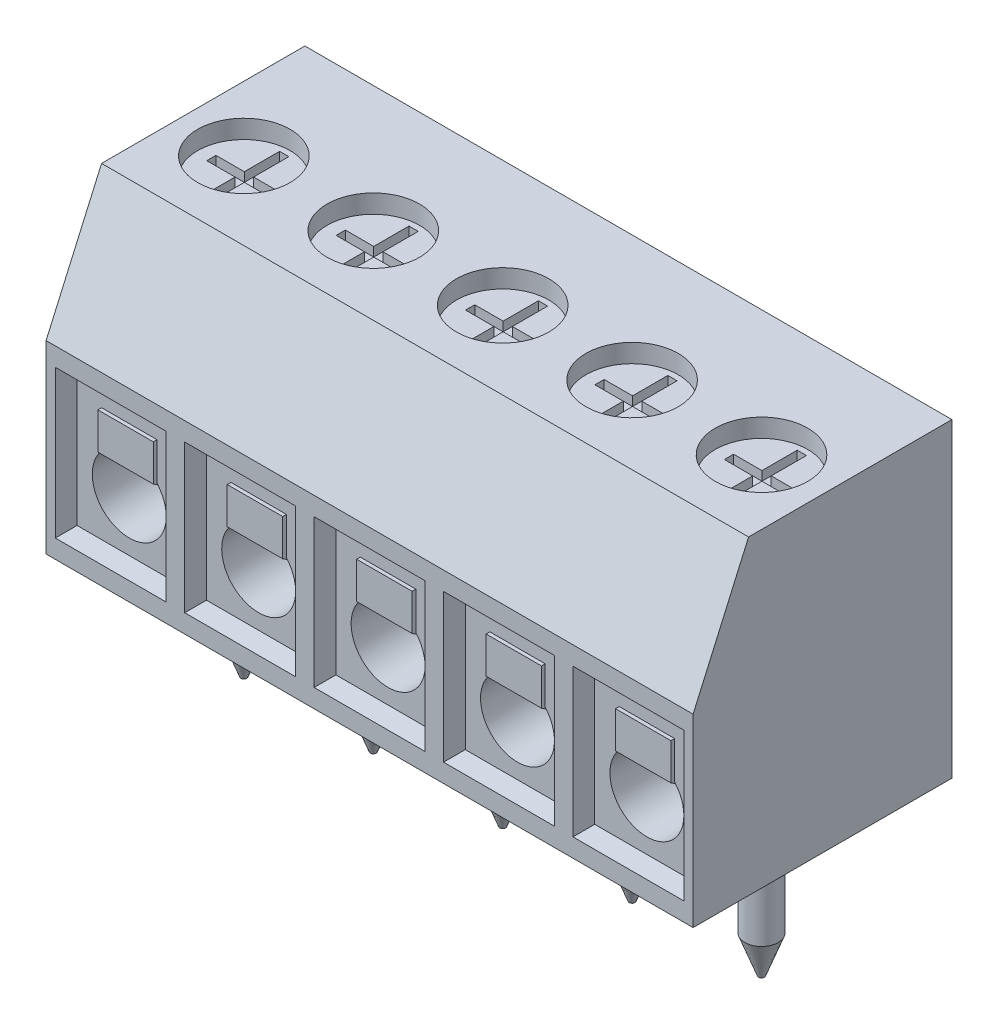
from build123d import *

# Parameters (mm, degrees)
BOSS_EXTRUDE1_DEPTH         = 17.5
SKETCH2_R                   = 1.25
CUT_EXTRUDE1_DEPTH          = 0.5
SKETCH3_W                   = 3
SKETCH3_H                   = 4
CUT_EXTRUDE2_DEPTH          = 0.5
CUT_EXTRUDE2_TAPER          = 10
SKETCH4_R                   = 1
CUT_EXTRUDE3_DEPTH          = 6
SKETCH6_R                   = 0.45
BOSS_EXTRUDE3_DEPTH         = 3.8
CHAMFER1_SIZE               = 1
CHAMFER1_SIZE2              = 0.371896666
EXTRUDE_THIN1_DEPTH         = 0.75
SKETCH8_W                   = 0.25
SKETCH8_H                   = 2.158330758
SKETCH8_W_2                 = 1.874325027
SKETCH8_H_2                 = 0.25
CUT_EXTRUDE_THIN1_DEPTH     = 0.25
LPATTERN1_COUNT             = 5
LPATTERN1_PITCH             = 3.5
CHAMFER1_OF_LPATTERN1_SIZE2 = 0.371896666
CHAMFER1_OF_LPATTERN1_SIZE  = 1


with BuildPart() as part:
    # Sketch1 → Boss-Extrude1 (new body)
    with BuildSketch(Plane(origin=(0, 0, 0), x_dir=(0, 0, -1), z_dir=(1, 0, 0))):
        Polygon((0, 5), (1.5, 8.4), (7, 8.4), (7, 0), (0, 0), align=None)
    extrude(amount=BOSS_EXTRUDE1_DEPTH)

    # Sketch2 → Cut-Extrude1 (cut)
    with BuildSketch(Plane(origin=(0, 8.4, 0), x_dir=(1, 0, 0), z_dir=(0, 1, 0))):
        with Locations((1.75, 3.6)):
            Circle(SKETCH2_R)
    cut_extrude1 = extrude(amount=-CUT_EXTRUDE1_DEPTH, mode=Mode.SUBTRACT)

    # Sketch3 → Cut-Extrude2 (cut)
    with BuildSketch(Plane.XY):
        with Locations((1.75, 2.5)):
            Rectangle(SKETCH3_W, SKETCH3_H)
    cut_extrude2 = extrude(amount=-CUT_EXTRUDE2_DEPTH, taper=CUT_EXTRUDE2_TAPER, mode=Mode.SUBTRACT)

    # Sketch4 → Cut-Extrude3 (cut)
    with BuildSketch(Plane.XY.offset(-0.5)):
        with Locations((1.75, 2)):
            Circle(SKETCH4_R)
    cut_extrude3 = extrude(amount=-CUT_EXTRUDE3_DEPTH, mode=Mode.SUBTRACT)

    # Sketch6 → Boss-Extrude3 (add)
    with BuildSketch(Plane.XZ):
        with Locations((1.75, -3.6)):
            Circle(SKETCH6_R)
    boss_extrude3 = extrude(amount=BOSS_EXTRUDE3_DEPTH)

    # Chamfer1
    chamfer1_edges = [part.edges().sort_by_distance(p)[0] for p in [
        (1.3, -3.8, -3.6),
    ]]
    chamfer1_side = [part.faces().sort_by_distance(p)[0] for p in [
        (1.3, -1.9, -3.6),
    ]]
    chamfer(chamfer1_edges, length=CHAMFER1_SIZE, length2=CHAMFER1_SIZE2, reference=chamfer1_side[0])

    # Sketch7 → Extrude-Thin1 (add, symmetric)
    with BuildSketch(Plane(origin=(1.75, 0, 0), x_dir=(0, 0, -1), z_dir=(1, 0, 0))):
        Polygon((0.5, 3.678716588), (0.5, 2.743158903), (1.89970396, 1.832221158), (5.88813409, 1.438302133), (5.878305368, 1.338786324), (1.865601336, 1.735102771), (0.4, 2.688927019), (0.4, 3.678716588), align=None)
    extrude_thin1 = extrude(amount=EXTRUDE_THIN1_DEPTH, both=True)

    # Sketch8 → Cut-Extrude-Thin1 (cut, symmetric)
    with BuildSketch(Plane(origin=(0, 7.9, 0), x_dir=(1, 0, 0), z_dir=(0, 1, 0))):
        with Locations((1.75, 3.611637798)):
            Rectangle(SKETCH8_W, SKETCH8_H)
        with Locations((1.795143175, 3.611637798)):
            Rectangle(SKETCH8_W_2, SKETCH8_H_2)
    cut_extrude_thin1 = extrude(amount=CUT_EXTRUDE_THIN1_DEPTH, both=True, mode=Mode.SUBTRACT)

    # LPattern1: Cut-Extrude1, Cut-Extrude2, Cut-Extrude3, Boss-Extrude3, Extrude-Thin1, Cut-Extrude-Thin1 ×5
    with Locations(*[(i * LPATTERN1_PITCH, 0, 0) for i in range(1, LPATTERN1_COUNT)]):
        add(cut_extrude1, mode=Mode.SUBTRACT)
        add(cut_extrude2, mode=Mode.SUBTRACT)
        add(cut_extrude3, mode=Mode.SUBTRACT)
        add(boss_extrude3)
        add(extrude_thin1)
        add(cut_extrude_thin1, mode=Mode.SUBTRACT)

    # Chamfer1 of LPattern1
    chamfer1_of_lpattern1_edges = [part.edges().sort_by_distance(p)[0] for p in [
        (4.8, -3.8, -3.6),
        (8.3, -3.8, -3.6),
        (11.8, -3.8, -3.6),
        (15.3, -3.8, -3.6),
    ]]
    chamfer(chamfer1_of_lpattern1_edges, length=CHAMFER1_OF_LPATTERN1_SIZE, length2=CHAMFER1_OF_LPATTERN1_SIZE2)


solid = part.part
